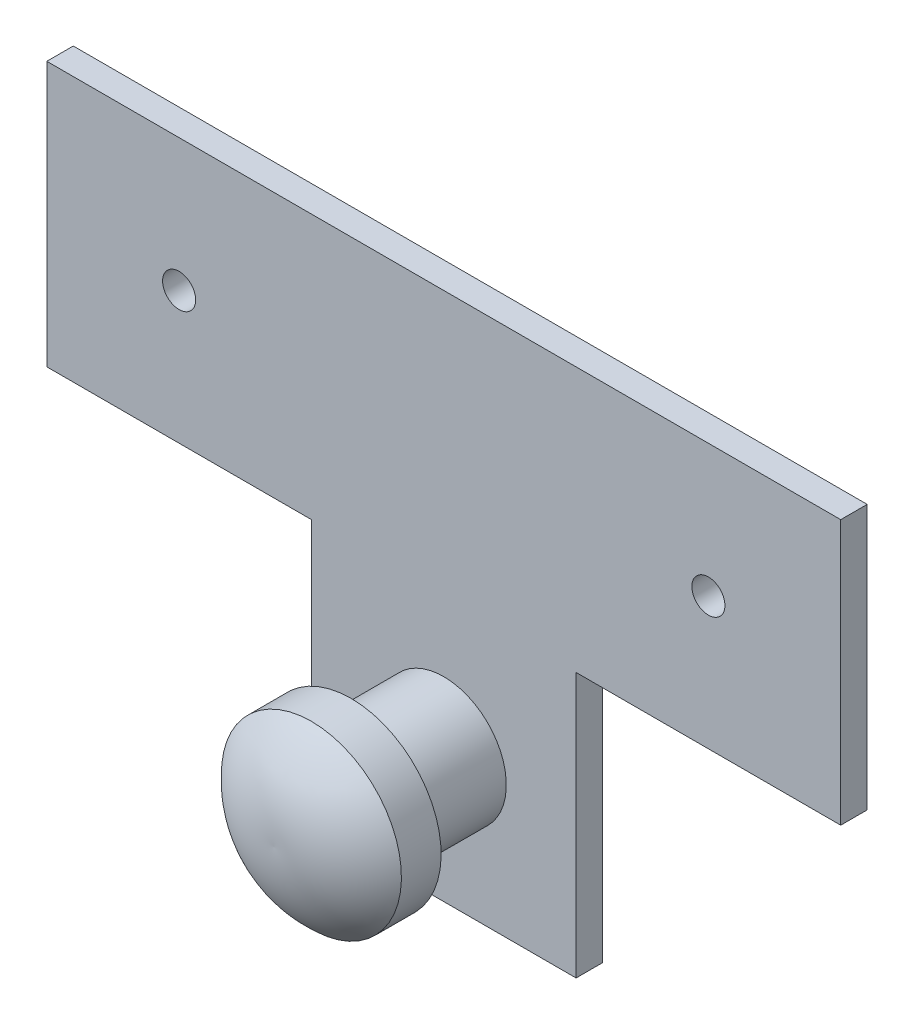
from build123d import *

# Parameters (mm, degrees)
BOSS_EXTRUDE1_DEPTH = 2.54
SKETCH2_R           = 6
BOSS_EXTRUDE2_DEPTH = 8.89
CUT_EXTRUDE1_REACH  = 20.872
SKETCH5_R           = 1.5875


with BuildPart() as part:
    # Sketch1 → Boss-Extrude1 (new body)
    with BuildSketch(Plane.XY):
        Polygon((12.7, 0), (38.1, 0), (38.1, 25.4), (-38.1, 25.4), (-38.1, 0), (-12.7, 0), (-12.7, -25.4), (12.7, -25.4), align=None)
    extrude(amount=BOSS_EXTRUDE1_DEPTH)

    # Sketch2 → Boss-Extrude2 (add)
    with BuildSketch(Plane.XY.offset(2.54)):
        with Locations((0, -12.7)):
            Circle(SKETCH2_R)
    extrude(amount=BOSS_EXTRUDE2_DEPTH)

    # Sketch4 → Revolve1 (revolve)
    with BuildSketch(Plane(origin=(0, 0, 0), x_dir=(0, 0, -1), z_dir=(1, 0, 0))):
        with BuildLine():
            Line((-11.43, -12.7), (-18.854523239, -12.7))
            ThreePointArc((-18.854523239, -12.7), (-18.044308382, -17.435305314), (-15.24, -21.336))
            Line((-15.24, -21.336), (-11.43, -21.336))
            Line((-11.43, -21.336), (-11.43, -12.7))
        make_face()
    revolve(axis=Axis((0, -12.7, 11.43), (0, 0, 1)))

    # Sketch5 → Cut-Extrude1 (cut, up to next)
    with BuildSketch(Plane(origin=(0, 0, 0), x_dir=(-1, 0, 0), z_dir=(0, 0, -1)), mode=Mode.PRIVATE) as cut_extrude1_sk1:
        with Locations((25.4, 12.7)):
            Circle(SKETCH5_R)
    cut_extrude1_tool1 = extrude(cut_extrude1_sk1.sketch, amount=-CUT_EXTRUDE1_REACH, mode=Mode.PRIVATE) & part.part
    add(cut_extrude1_tool1.solids().sort_by_distance((-25.4, 12.7, 0))[0], mode=Mode.SUBTRACT)
    # Sketch5 → Cut-Extrude1 (cut, up to next)
    with BuildSketch(Plane(origin=(0, 0, 0), x_dir=(-1, 0, 0), z_dir=(0, 0, -1)), mode=Mode.PRIVATE) as cut_extrude1_sk2:
        with Locations((-25.4, 12.7)):
            Circle(SKETCH5_R)
    cut_extrude1_tool2 = extrude(cut_extrude1_sk2.sketch, amount=-CUT_EXTRUDE1_REACH, mode=Mode.PRIVATE) & part.part
    add(cut_extrude1_tool2.solids().sort_by_distance((25.4, 12.7, 0))[0], mode=Mode.SUBTRACT)


solid = part.part
